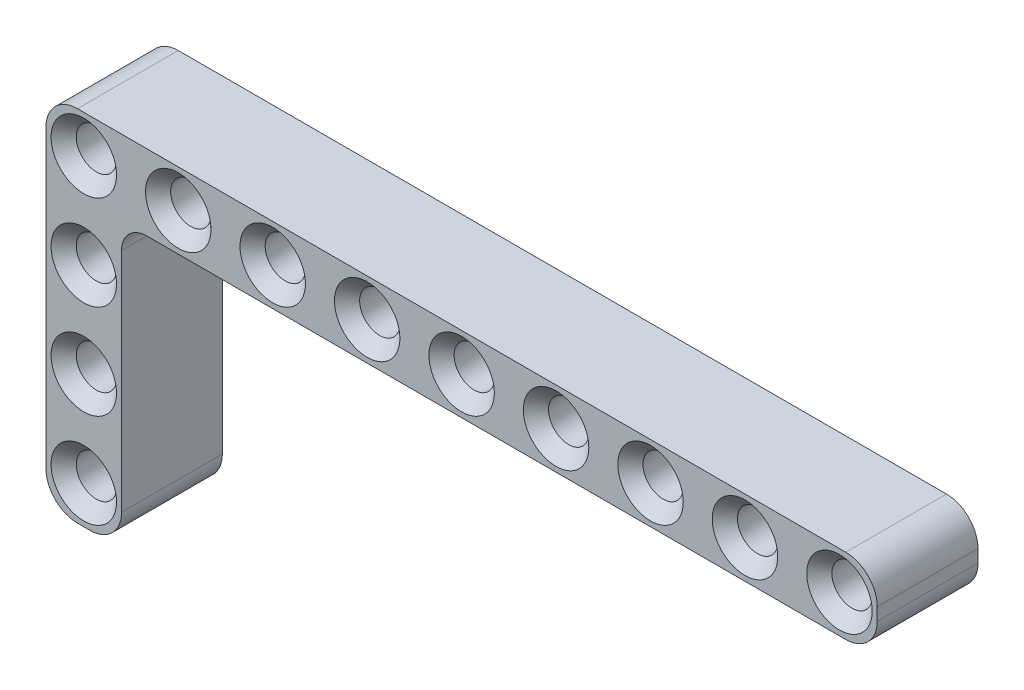
from build123d import *

# Parameters (mm, degrees)
SKETCH1_R           = 1.6
BOSS_EXTRUDE1_DEPTH = 8
CHAMFER1_SIZE       = 1
SKETCH2_R           = 1.6
BOSS_EXTRUDE3_DEPTH = 8
FILLET1_R           = 2
CHAMFER3_SIZE       = 1
CHAMFER4_SIZE       = 1
CHAMFER5_SIZE       = 1


with BuildPart() as part:
    # Sketch1 → Boss-Extrude1 (new body)
    with BuildSketch(Plane.XY):
        with BuildLine():
            Line((-0.5, 3), (60.5, 3))
            ThreePointArc((60.5, 3), (62.267766953, 2.267766953), (63, 0.5))
            Line((63, 0.5), (63, -0.5))
            ThreePointArc((63, -0.5), (62.267766953, -2.267766953), (60.5, -3))
            Line((60.5, -3), (-0.5, -3))
            ThreePointArc((-0.5, -3), (-2.267766953, -2.267766953), (-3, -0.5))
            Line((-3, -0.5), (-3, 0.5))
            ThreePointArc((-3, 0.5), (-2.267766953, 2.267766953), (-0.5, 3))
        make_face()
        Circle(SKETCH1_R, mode=Mode.SUBTRACT)
        with Locations((7.5, 0)):
            Circle(SKETCH1_R, mode=Mode.SUBTRACT)
        with Locations((15, 0)):
            Circle(SKETCH1_R, mode=Mode.SUBTRACT)
        with Locations((22.5, 0)):
            Circle(SKETCH1_R, mode=Mode.SUBTRACT)
        with Locations((30, 0)):
            Circle(SKETCH1_R, mode=Mode.SUBTRACT)
        with Locations((37.5, 0)):
            Circle(SKETCH1_R, mode=Mode.SUBTRACT)
        with Locations((45, 0)):
            Circle(SKETCH1_R, mode=Mode.SUBTRACT)
        with Locations((52.5, 0)):
            Circle(SKETCH1_R, mode=Mode.SUBTRACT)
        with Locations((60, 0)):
            Circle(SKETCH1_R, mode=Mode.SUBTRACT)
    extrude(amount=BOSS_EXTRUDE1_DEPTH)

    # Chamfer1
    chamfer1_edges = [part.edges().sort_by_distance(p)[0] for p in [
        (-1.6, 0, 0),
        (-1.6, 0, 8),
        (5.9, 0, 0),
        (5.9, 0, 8),
        (13.4, 0, 0),
        (13.4, 0, 8),
        (20.9, 0, 0),
        (20.9, 0, 8),
        (28.4, 0, 0),
        (28.4, 0, 8),
    ]]
    chamfer(chamfer1_edges, length=CHAMFER1_SIZE)

    # Sketch2 → Boss-Extrude3 (add)
    with BuildSketch(Plane.XY.offset(8)):
        with BuildLine():
            ThreePointArc((-0.5, -3), (-2.267766953, -2.267766953), (-3, -0.5))
            Line((-3, -0.5), (-3, -23))
            ThreePointArc((-3, -23), (-2.267766953, -24.767766953), (-0.5, -25.5))
            Line((-0.5, -25.5), (0.5, -25.5))
            ThreePointArc((0.5, -25.5), (2.267766953, -24.767766953), (3, -23))
            Line((3, -23), (3, -3))
            Line((3, -3), (-0.5, -3))
        make_face()
        with Locations((0, -22.5)):
            Circle(SKETCH2_R, mode=Mode.SUBTRACT)
        with Locations((0, -15)):
            Circle(SKETCH2_R, mode=Mode.SUBTRACT)
        with Locations((0, -7.5)):
            Circle(SKETCH2_R, mode=Mode.SUBTRACT)
    extrude(amount=-BOSS_EXTRUDE3_DEPTH)

    # Fillet1
    fillet1_edges = [part.edges().sort_by_distance(p)[0] for p in [
        (3, -3, 4),
    ]]
    fillet(fillet1_edges, radius=FILLET1_R)

    # Chamfer3
    chamfer3_edges = [part.edges().sort_by_distance(p)[0] for p in [
        (35.9, 0, 0),
        (35.9, 0, 8),
        (43.4, 0, 0),
        (43.4, 0, 8),
    ]]
    chamfer(chamfer3_edges, length=CHAMFER3_SIZE)

    # Chamfer4
    chamfer4_edges = [part.edges().sort_by_distance(p)[0] for p in [
        (50.9, 0, 0),
        (50.9, 0, 8),
        (58.4, 0, 0),
        (58.4, 0, 8),
    ]]
    chamfer(chamfer4_edges, length=CHAMFER4_SIZE)

    # Chamfer5
    chamfer5_edges = [part.edges().sort_by_distance(p)[0] for p in [
        (-1.6, -7.5, 8),
        (-1.6, -15, 8),
        (-1.6, -22.5, 8),
        (-1.6, -22.5, 0),
        (-1.6, -15, 0),
        (-1.6, -7.5, 0),
    ]]
    chamfer(chamfer5_edges, length=CHAMFER5_SIZE)


solid = part.part
